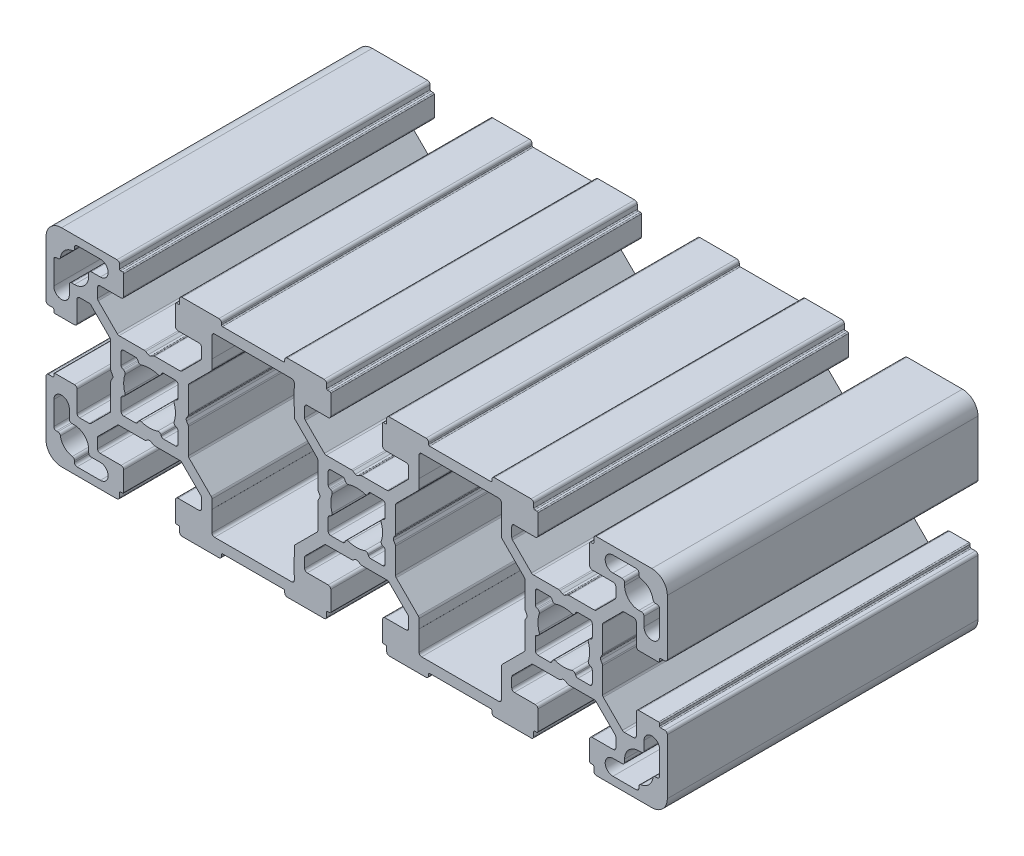
from build123d import *

# Parameters (mm, degrees)
EXTRUDE_1_DEPTH = 60


with BuildPart() as part:
    # Эскиз1 → Бобышка-Вытянуть1 (new body)
    with BuildSketch(Plane.XY):
        with BuildLine():
            Line((-52.669436616, 65.991989417), (-53.169436616, 65.703314282))
            ThreePointArc((-53.169436616, 65.703314282), (-53.419436616, 65.636326984), (-53.669436616, 65.703314282))
            Line((-53.669436616, 65.703314282), (-54.169436616, 65.991989417))
            ThreePointArc((-54.169436616, 65.991989417), (-54.290027094, 66.041939628), (-54.419436616, 66.058976715))
            Line((-54.419436616, 66.058976715), (-59.298116273, 66.058976715))
            ThreePointArc((-59.298116273, 66.058976715), (-59.489457989, 66.097036949), (-59.651669663, 66.205423324))
            Line((-59.651669663, 66.205423324), (-63.322990007, 69.876743668))
            ThreePointArc((-63.322990007, 69.876743668), (-63.431376383, 70.038955342), (-63.469436616, 70.230297059))
            Line((-63.469436616, 70.230297059), (-63.469436616, 72.058976715))
            ThreePointArc((-63.469436616, 72.058976715), (-63.322990007, 72.412530106), (-62.969436616, 72.558976715))
            Line((-62.969436616, 72.558976715), (-58.919436616, 72.558976715))
            ThreePointArc((-58.919436616, 72.558976715), (-58.565883226, 72.705423324), (-58.419436616, 73.058976715))
            Line((-58.419436616, 73.058976715), (-58.419436616, 76.858976715))
            ThreePointArc((-58.419436616, 76.858976715), (-58.47801526, 77.000398071), (-58.619436616, 77.058976715))
            Line((-58.619436616, 77.058976715), (-59.019436616, 77.058976715))
            ThreePointArc((-59.019436616, 77.058976715), (-59.160857973, 77.117555359), (-59.219436616, 77.258976715))
            Line((-59.219436616, 77.258976715), (-59.219436616, 78.058976715))
            ThreePointArc((-59.219436616, 78.058976715), (-59.365883226, 78.412530106), (-59.719436616, 78.558976715))
            Line((-59.719436616, 78.558976715), (-70.419436616, 78.558976715))
            ThreePointArc((-70.419436616, 78.558976715), (-72.54075696, 77.680297059), (-73.419436616, 75.558976715))
            Line((-73.419436616, 75.558976715), (-73.419436616, 64.858976715))
            ThreePointArc((-73.419436616, 64.858976715), (-73.272990007, 64.505423324), (-72.919436616, 64.358976715))
            Line((-72.919436616, 64.358976715), (-72.119436616, 64.358976715))
            ThreePointArc((-72.119436616, 64.358976715), (-71.97801526, 64.300398071), (-71.919436616, 64.158976715))
            Line((-71.919436616, 64.158976715), (-71.919436616, 63.758976715))
            ThreePointArc((-71.919436616, 63.758976715), (-71.860857973, 63.617555359), (-71.719436616, 63.558976715))
            Line((-71.719436616, 63.558976715), (-67.919436616, 63.558976715))
            ThreePointArc((-67.919436616, 63.558976715), (-67.565883226, 63.705423324), (-67.419436616, 64.058976715))
            Line((-67.419436616, 64.058976715), (-67.419436616, 68.108976715))
            ThreePointArc((-67.419436616, 68.108976715), (-67.272990007, 68.462530106), (-66.919436616, 68.608976715))
            Line((-66.919436616, 68.608976715), (-65.09075696, 68.608976715))
            ThreePointArc((-65.09075696, 68.608976715), (-64.899415244, 68.570916481), (-64.737203569, 68.462530106))
            Line((-64.737203569, 68.462530106), (-61.065883226, 64.791209762))
            ThreePointArc((-61.065883226, 64.791209762), (-60.95749685, 64.628998088), (-60.919436616, 64.437656371))
            Line((-60.919436616, 64.437656371), (-60.919436616, 59.558976715))
            ThreePointArc((-60.919436616, 59.558976715), (-60.90239953, 59.429567192), (-60.852449318, 59.308976715))
            Line((-60.852449318, 59.308976715), (-60.563774184, 58.808976715))
            ThreePointArc((-60.563774184, 58.808976715), (-60.496786886, 58.558976715), (-60.563774184, 58.308976715))
            Line((-60.563774184, 58.308976715), (-60.852449318, 57.808976715))
            ThreePointArc((-60.852449318, 57.808976715), (-60.90239953, 57.688386237), (-60.919436616, 57.558976715))
            Line((-60.919436616, 57.558976715), (-60.919436616, 52.680297059))
            ThreePointArc((-60.919436616, 52.680297059), (-60.95749685, 52.488955342), (-61.065883226, 52.326743668))
            Line((-61.065883226, 52.326743668), (-64.737203569, 48.655423324))
            ThreePointArc((-64.737203569, 48.655423324), (-64.899415244, 48.547036949), (-65.09075696, 48.508976715))
            Line((-65.09075696, 48.508976715), (-66.919436616, 48.508976715))
            ThreePointArc((-66.919436616, 48.508976715), (-67.272990007, 48.655423324), (-67.419436616, 49.008976715))
            Line((-67.419436616, 49.008976715), (-67.419436616, 53.058976715))
            ThreePointArc((-67.419436616, 53.058976715), (-67.565883226, 53.412530106), (-67.919436616, 53.558976715))
            Line((-67.919436616, 53.558976715), (-71.719436616, 53.558976715))
            ThreePointArc((-71.719436616, 53.558976715), (-71.860857973, 53.500398071), (-71.919436616, 53.358976715))
            Line((-71.919436616, 53.358976715), (-71.919436616, 52.958976715))
            ThreePointArc((-71.919436616, 52.958976715), (-71.97801526, 52.817555359), (-72.119436616, 52.758976715))
            Line((-72.119436616, 52.758976715), (-72.919436616, 52.758976715))
            ThreePointArc((-72.919436616, 52.758976715), (-73.272990007, 52.612530106), (-73.419436616, 52.258976715))
            Line((-73.419436616, 52.258976715), (-73.419436616, 41.558976715))
            ThreePointArc((-73.419436616, 41.558976715), (-72.54075696, 39.437656371), (-70.419436616, 38.558976715))
            Line((-70.419436616, 38.558976715), (-59.719436616, 38.558976715))
            ThreePointArc((-59.719436616, 38.558976715), (-59.365883226, 38.705423324), (-59.219436616, 39.058976715))
            Line((-59.219436616, 39.058976715), (-59.219436616, 39.858976715))
            ThreePointArc((-59.219436616, 39.858976715), (-59.160857973, 40.000398071), (-59.019436616, 40.058976715))
            Line((-59.019436616, 40.058976715), (-58.619436616, 40.058976715))
            ThreePointArc((-58.619436616, 40.058976715), (-58.47801526, 40.117555359), (-58.419436616, 40.258976715))
            Line((-58.419436616, 40.258976715), (-58.419436616, 44.058976715))
            ThreePointArc((-58.419436616, 44.058976715), (-58.565883226, 44.412530106), (-58.919436616, 44.558976715))
            Line((-58.919436616, 44.558976715), (-62.969436616, 44.558976715))
            ThreePointArc((-62.969436616, 44.558976715), (-63.322990007, 44.705423324), (-63.469436616, 45.058976715))
            Line((-63.469436616, 45.058976715), (-63.469436616, 46.887656371))
            ThreePointArc((-63.469436616, 46.887656371), (-63.431376383, 47.078998088), (-63.322990007, 47.241209762))
            Line((-63.322990007, 47.241209762), (-59.651669663, 50.912530106))
            ThreePointArc((-59.651669663, 50.912530106), (-59.489457989, 51.020916481), (-59.298116273, 51.058976715))
            Line((-59.298116273, 51.058976715), (-54.419436616, 51.058976715))
            ThreePointArc((-54.419436616, 51.058976715), (-54.290027094, 51.076013802), (-54.169436616, 51.125964013))
            Line((-54.169436616, 51.125964013), (-53.669436616, 51.414639148))
            ThreePointArc((-53.669436616, 51.414639148), (-53.419436616, 51.481626446), (-53.169436616, 51.414639148))
            Line((-53.169436616, 51.414639148), (-52.669436616, 51.125964013))
            ThreePointArc((-52.669436616, 51.125964013), (-52.548846139, 51.076013802), (-52.419436616, 51.058976715))
            Line((-52.419436616, 51.058976715), (-47.54075696, 51.058976715))
            ThreePointArc((-47.54075696, 51.058976715), (-47.349415244, 51.020916481), (-47.187203569, 50.912530106))
            Line((-47.187203569, 50.912530106), (-43.515883226, 47.241209762))
            ThreePointArc((-43.515883226, 47.241209762), (-43.40749685, 47.078998088), (-43.369436616, 46.887656371))
            Line((-43.369436616, 46.887656371), (-43.369436616, 45.058976715))
            ThreePointArc((-43.369436616, 45.058976715), (-43.515883226, 44.705423324), (-43.869436616, 44.558976715))
            Line((-43.869436616, 44.558976715), (-47.919436616, 44.558976715))
            ThreePointArc((-47.919436616, 44.558976715), (-48.272990007, 44.412530106), (-48.419436616, 44.058976715))
            Line((-48.419436616, 44.058976715), (-48.419436616, 40.258976715))
            ThreePointArc((-48.419436616, 40.258976715), (-48.360857973, 40.117555359), (-48.219436616, 40.058976715))
            Line((-48.219436616, 40.058976715), (-47.819436616, 40.058976715))
            ThreePointArc((-47.819436616, 40.058976715), (-47.67801526, 40.000398071), (-47.619436616, 39.858976715))
            Line((-47.619436616, 39.858976715), (-47.619436616, 39.058976715))
            ThreePointArc((-47.619436616, 39.058976715), (-47.472990007, 38.705423324), (-47.119436616, 38.558976715))
            Line((-47.119436616, 38.558976715), (-40.029436616, 38.558976715))
            ThreePointArc((-40.029436616, 38.558976715), (-39.675883226, 38.705423324), (-39.529436616, 39.058976715))
            Line((-39.529436616, 39.058976715), (-39.529436616, 39.358976715))
            ThreePointArc((-39.529436616, 39.358976715), (-39.470857973, 39.500398071), (-39.329436616, 39.558976715))
            Line((-39.329436616, 39.558976715), (-27.509436616, 39.558976715))
            ThreePointArc((-27.509436616, 39.558976715), (-27.36801526, 39.500398071), (-27.309436616, 39.358976715))
            Line((-27.309436616, 39.358976715), (-27.309436616, 39.058976715))
            ThreePointArc((-27.309436616, 39.058976715), (-27.162990007, 38.705423324), (-26.809436616, 38.558976715))
            Line((-26.809436616, 38.558976715), (-19.719436616, 38.558976715))
            ThreePointArc((-19.719436616, 38.558976715), (-19.365883226, 38.705423324), (-19.219436616, 39.058976715))
            Line((-19.219436616, 39.058976715), (-19.219436616, 39.858976715))
            ThreePointArc((-19.219436616, 39.858976715), (-19.160857973, 40.000398071), (-19.019436616, 40.058976715))
            Line((-19.019436616, 40.058976715), (-18.619436616, 40.058976715))
            ThreePointArc((-18.619436616, 40.058976715), (-18.47801526, 40.117555359), (-18.419436616, 40.258976715))
            Line((-18.419436616, 40.258976715), (-18.419436616, 44.058976715))
            ThreePointArc((-18.419436616, 44.058976715), (-18.565883226, 44.412530106), (-18.919436616, 44.558976715))
            Line((-18.919436616, 44.558976715), (-22.969436616, 44.558976715))
            ThreePointArc((-22.969436616, 44.558976715), (-23.322990007, 44.705423324), (-23.469436616, 45.058976715))
            Line((-23.469436616, 45.058976715), (-23.469436616, 46.887656371))
            ThreePointArc((-23.469436616, 46.887656371), (-23.431376383, 47.078998088), (-23.322990007, 47.241209762))
            Line((-23.322990007, 47.241209762), (-19.651669663, 50.912530106))
            ThreePointArc((-19.651669663, 50.912530106), (-19.489457989, 51.020916481), (-19.298116273, 51.058976715))
            Line((-19.298116273, 51.058976715), (-14.419436616, 51.058976715))
            ThreePointArc((-14.419436616, 51.058976715), (-14.290027094, 51.076013802), (-14.169436616, 51.125964013))
            Line((-14.169436616, 51.125964013), (-13.669436616, 51.414639148))
            ThreePointArc((-13.669436616, 51.414639148), (-13.419436616, 51.481626446), (-13.169436616, 51.414639148))
            Line((-13.169436616, 51.414639148), (-12.669436616, 51.125964013))
            ThreePointArc((-12.669436616, 51.125964013), (-12.548846139, 51.076013802), (-12.419436616, 51.058976715))
            Line((-12.419436616, 51.058976715), (-7.54075696, 51.058976715))
            ThreePointArc((-7.54075696, 51.058976715), (-7.349415244, 51.020916481), (-7.187203569, 50.912530106))
            Line((-7.187203569, 50.912530106), (-3.515883226, 47.241209762))
            ThreePointArc((-3.515883226, 47.241209762), (-3.40749685, 47.078998088), (-3.369436616, 46.887656371))
            Line((-3.369436616, 46.887656371), (-3.369436616, 45.058976715))
            ThreePointArc((-3.369436616, 45.058976715), (-3.515883226, 44.705423324), (-3.869436616, 44.558976715))
            Line((-3.869436616, 44.558976715), (-7.919436616, 44.558976715))
            ThreePointArc((-7.919436616, 44.558976715), (-8.272990007, 44.412530106), (-8.419436616, 44.058976715))
            Line((-8.419436616, 44.058976715), (-8.419436616, 40.258976715))
            ThreePointArc((-8.419436616, 40.258976715), (-8.360857973, 40.117555359), (-8.219436616, 40.058976715))
            Line((-8.219436616, 40.058976715), (-7.819436616, 40.058976715))
            ThreePointArc((-7.819436616, 40.058976715), (-7.67801526, 40.000398071), (-7.619436616, 39.858976715))
            Line((-7.619436616, 39.858976715), (-7.619436616, 39.058976715))
            ThreePointArc((-7.619436616, 39.058976715), (-7.472990007, 38.705423324), (-7.119436616, 38.558976715))
            Line((-7.119436616, 38.558976715), (-0.029436616, 38.558976715))
            ThreePointArc((-0.029436616, 38.558976715), (0.324116774, 38.705423324), (0.470563384, 39.058976715))
            Line((0.470563384, 39.058976715), (0.470563384, 39.358976715))
            ThreePointArc((0.470563384, 39.358976715), (0.529142027, 39.500398071), (0.670563384, 39.558976715))
            Line((0.670563384, 39.558976715), (12.490563384, 39.558976715))
            ThreePointArc((12.490563384, 39.558976715), (12.63198474, 39.500398071), (12.690563384, 39.358976715))
            Line((12.690563384, 39.358976715), (12.690563384, 39.058976715))
            ThreePointArc((12.690563384, 39.058976715), (12.837009993, 38.705423324), (13.190563384, 38.558976715))
            Line((13.190563384, 38.558976715), (20.280563384, 38.558976715))
            ThreePointArc((20.280563384, 38.558976715), (20.634116774, 38.705423324), (20.780563384, 39.058976715))
            Line((20.780563384, 39.058976715), (20.780563384, 39.858976715))
            ThreePointArc((20.780563384, 39.858976715), (20.839142027, 40.000398071), (20.980563384, 40.058976715))
            Line((20.980563384, 40.058976715), (21.380563384, 40.058976715))
            ThreePointArc((21.380563384, 40.058976715), (21.52198474, 40.117555359), (21.580563384, 40.258976715))
            Line((21.580563384, 40.258976715), (21.580563384, 44.058976715))
            ThreePointArc((21.580563384, 44.058976715), (21.434116774, 44.412530106), (21.080563384, 44.558976715))
            Line((21.080563384, 44.558976715), (17.030563384, 44.558976715))
            ThreePointArc((17.030563384, 44.558976715), (16.677009993, 44.705423324), (16.530563384, 45.058976715))
            Line((16.530563384, 45.058976715), (16.530563384, 46.887656371))
            ThreePointArc((16.530563384, 46.887656371), (16.568623617, 47.078998088), (16.677009993, 47.241209762))
            Line((16.677009993, 47.241209762), (20.348330337, 50.912530106))
            ThreePointArc((20.348330337, 50.912530106), (20.510542011, 51.020916481), (20.701883727, 51.058976715))
            Line((20.701883727, 51.058976715), (25.580563384, 51.058976715))
            ThreePointArc((25.580563384, 51.058976715), (25.709972906, 51.076013802), (25.830563384, 51.125964013))
            Line((25.830563384, 51.125964013), (26.330563384, 51.414639148))
            ThreePointArc((26.330563384, 51.414639148), (26.580563384, 51.481626446), (26.830563384, 51.414639148))
            Line((26.830563384, 51.414639148), (27.330563384, 51.125964013))
            ThreePointArc((27.330563384, 51.125964013), (27.451153861, 51.076013802), (27.580563384, 51.058976715))
            Line((27.580563384, 51.058976715), (32.45924304, 51.058976715))
            ThreePointArc((32.45924304, 51.058976715), (32.650584756, 51.020916481), (32.812796431, 50.912530106))
            Line((32.812796431, 50.912530106), (36.484116774, 47.241209762))
            ThreePointArc((36.484116774, 47.241209762), (36.59250315, 47.078998088), (36.630563384, 46.887656371))
            Line((36.630563384, 46.887656371), (36.630563384, 45.058976715))
            ThreePointArc((36.630563384, 45.058976715), (36.484116774, 44.705423324), (36.130563384, 44.558976715))
            Line((36.130563384, 44.558976715), (32.080563384, 44.558976715))
            ThreePointArc((32.080563384, 44.558976715), (31.727009993, 44.412530106), (31.580563384, 44.058976715))
            Line((31.580563384, 44.058976715), (31.580563384, 40.258976715))
            ThreePointArc((31.580563384, 40.258976715), (31.639142027, 40.117555359), (31.780563384, 40.058976715))
            Line((31.780563384, 40.058976715), (32.180563384, 40.058976715))
            ThreePointArc((32.180563384, 40.058976715), (32.32198474, 40.000398071), (32.380563384, 39.858976715))
            Line((32.380563384, 39.858976715), (32.380563384, 39.058976715))
            ThreePointArc((32.380563384, 39.058976715), (32.527009993, 38.705423324), (32.880563384, 38.558976715))
            Line((32.880563384, 38.558976715), (43.580563384, 38.558976715))
            ThreePointArc((43.580563384, 38.558976715), (45.701883727, 39.437656371), (46.580563384, 41.558976715))
            Line((46.580563384, 41.558976715), (46.580563384, 52.258976715))
            ThreePointArc((46.580563384, 52.258976715), (46.434116774, 52.612530106), (46.080563384, 52.758976715))
            Line((46.080563384, 52.758976715), (45.280563384, 52.758976715))
            ThreePointArc((45.280563384, 52.758976715), (45.139142027, 52.817555359), (45.080563384, 52.958976715))
            Line((45.080563384, 52.958976715), (45.080563384, 53.358976715))
            ThreePointArc((45.080563384, 53.358976715), (45.02198474, 53.500398071), (44.880563384, 53.558976715))
            Line((44.880563384, 53.558976715), (41.080563384, 53.558976715))
            ThreePointArc((41.080563384, 53.558976715), (40.727009993, 53.412530106), (40.580563384, 53.058976715))
            Line((40.580563384, 53.058976715), (40.580563384, 49.008976715))
            ThreePointArc((40.580563384, 49.008976715), (40.434116774, 48.655423324), (40.080563384, 48.508976715))
            Line((40.080563384, 48.508976715), (38.251883727, 48.508976715))
            ThreePointArc((38.251883727, 48.508976715), (38.060542011, 48.547036949), (37.898330337, 48.655423324))
            Line((37.898330337, 48.655423324), (34.227009993, 52.326743668))
            ThreePointArc((34.227009993, 52.326743668), (34.118623617, 52.488955342), (34.080563384, 52.680297059))
            Line((34.080563384, 52.680297059), (34.080563384, 57.558976715))
            ThreePointArc((34.080563384, 57.558976715), (34.063526297, 57.688386237), (34.013576086, 57.808976715))
            Line((34.013576086, 57.808976715), (33.724900951, 58.308976715))
            ThreePointArc((33.724900951, 58.308976715), (33.657913653, 58.558976715), (33.724900951, 58.808976715))
            Line((33.724900951, 58.808976715), (34.013576086, 59.308976715))
            ThreePointArc((34.013576086, 59.308976715), (34.063526297, 59.429567192), (34.080563384, 59.558976715))
            Line((34.080563384, 59.558976715), (34.080563384, 64.437656371))
            ThreePointArc((34.080563384, 64.437656371), (34.118623617, 64.628998088), (34.227009993, 64.791209762))
            Line((34.227009993, 64.791209762), (37.898330337, 68.462530106))
            ThreePointArc((37.898330337, 68.462530106), (38.060542011, 68.570916481), (38.251883727, 68.608976715))
            Line((38.251883727, 68.608976715), (40.080563384, 68.608976715))
            ThreePointArc((40.080563384, 68.608976715), (40.434116774, 68.462530106), (40.580563384, 68.108976715))
            Line((40.580563384, 68.108976715), (40.580563384, 64.058976715))
            ThreePointArc((40.580563384, 64.058976715), (40.727009993, 63.705423324), (41.080563384, 63.558976715))
            Line((41.080563384, 63.558976715), (44.880563384, 63.558976715))
            ThreePointArc((44.880563384, 63.558976715), (45.02198474, 63.617555359), (45.080563384, 63.758976715))
            Line((45.080563384, 63.758976715), (45.080563384, 64.158976715))
            ThreePointArc((45.080563384, 64.158976715), (45.139142027, 64.300398071), (45.280563384, 64.358976715))
            Line((45.280563384, 64.358976715), (46.080563384, 64.358976715))
            ThreePointArc((46.080563384, 64.358976715), (46.434116774, 64.505423324), (46.580563384, 64.858976715))
            Line((46.580563384, 64.858976715), (46.580563384, 75.558976715))
            ThreePointArc((46.580563384, 75.558976715), (45.701883727, 77.680297059), (43.580563384, 78.558976715))
            Line((43.580563384, 78.558976715), (32.880563384, 78.558976715))
            ThreePointArc((32.880563384, 78.558976715), (32.527009993, 78.412530106), (32.380563384, 78.058976715))
            Line((32.380563384, 78.058976715), (32.380563384, 77.258976715))
            ThreePointArc((32.380563384, 77.258976715), (32.32198474, 77.117555359), (32.180563384, 77.058976715))
            Line((32.180563384, 77.058976715), (31.780563384, 77.058976715))
            ThreePointArc((31.780563384, 77.058976715), (31.639142027, 77.000398071), (31.580563384, 76.858976715))
            Line((31.580563384, 76.858976715), (31.580563384, 73.058976715))
            ThreePointArc((31.580563384, 73.058976715), (31.727009993, 72.705423324), (32.080563384, 72.558976715))
            Line((32.080563384, 72.558976715), (36.130563384, 72.558976715))
            ThreePointArc((36.130563384, 72.558976715), (36.484116774, 72.412530106), (36.630563384, 72.058976715))
            Line((36.630563384, 72.058976715), (36.630563384, 70.230297059))
            ThreePointArc((36.630563384, 70.230297059), (36.59250315, 70.038955342), (36.484116774, 69.876743668))
            Line((36.484116774, 69.876743668), (32.812796431, 66.205423324))
            ThreePointArc((32.812796431, 66.205423324), (32.650584756, 66.097036949), (32.45924304, 66.058976715))
            Line((32.45924304, 66.058976715), (27.580563384, 66.058976715))
            ThreePointArc((27.580563384, 66.058976715), (27.451153861, 66.041939628), (27.330563384, 65.991989417))
            Line((27.330563384, 65.991989417), (26.830563384, 65.703314282))
            ThreePointArc((26.830563384, 65.703314282), (26.580563384, 65.636326984), (26.330563384, 65.703314282))
            Line((26.330563384, 65.703314282), (25.830563384, 65.991989417))
            ThreePointArc((25.830563384, 65.991989417), (25.709972906, 66.041939628), (25.580563384, 66.058976715))
            Line((25.580563384, 66.058976715), (20.701883727, 66.058976715))
            ThreePointArc((20.701883727, 66.058976715), (20.510542011, 66.097036949), (20.348330337, 66.205423324))
            Line((20.348330337, 66.205423324), (16.677009993, 69.876743668))
            ThreePointArc((16.677009993, 69.876743668), (16.568623617, 70.038955342), (16.530563384, 70.230297059))
            Line((16.530563384, 70.230297059), (16.530563384, 72.058976715))
            ThreePointArc((16.530563384, 72.058976715), (16.677009993, 72.412530106), (17.030563384, 72.558976715))
            Line((17.030563384, 72.558976715), (21.080563384, 72.558976715))
            ThreePointArc((21.080563384, 72.558976715), (21.434116774, 72.705423324), (21.580563384, 73.058976715))
            Line((21.580563384, 73.058976715), (21.580563384, 76.858976715))
            ThreePointArc((21.580563384, 76.858976715), (21.52198474, 77.000398071), (21.380563384, 77.058976715))
            Line((21.380563384, 77.058976715), (20.980563384, 77.058976715))
            ThreePointArc((20.980563384, 77.058976715), (20.839142027, 77.117555359), (20.780563384, 77.258976715))
            Line((20.780563384, 77.258976715), (20.780563384, 78.058976715))
            ThreePointArc((20.780563384, 78.058976715), (20.634116774, 78.412530106), (20.280563384, 78.558976715))
            Line((20.280563384, 78.558976715), (13.190563384, 78.558976715))
            ThreePointArc((13.190563384, 78.558976715), (12.837009993, 78.412530106), (12.690563384, 78.058976715))
            Line((12.690563384, 78.058976715), (12.690563384, 77.758976715))
            ThreePointArc((12.690563384, 77.758976715), (12.63198474, 77.617555359), (12.490563384, 77.558976715))
            Line((12.490563384, 77.558976715), (0.670563384, 77.558976715))
            ThreePointArc((0.670563384, 77.558976715), (0.529142027, 77.617555359), (0.470563384, 77.758976715))
            Line((0.470563384, 77.758976715), (0.470563384, 78.058976715))
            ThreePointArc((0.470563384, 78.058976715), (0.324116774, 78.412530106), (-0.029436616, 78.558976715))
            Line((-0.029436616, 78.558976715), (-7.119436616, 78.558976715))
            ThreePointArc((-7.119436616, 78.558976715), (-7.472990007, 78.412530106), (-7.619436616, 78.058976715))
            Line((-7.619436616, 78.058976715), (-7.619436616, 77.258976715))
            ThreePointArc((-7.619436616, 77.258976715), (-7.67801526, 77.117555359), (-7.819436616, 77.058976715))
            Line((-7.819436616, 77.058976715), (-8.219436616, 77.058976715))
            ThreePointArc((-8.219436616, 77.058976715), (-8.360857973, 77.000398071), (-8.419436616, 76.858976715))
            Line((-8.419436616, 76.858976715), (-8.419436616, 73.058976715))
            ThreePointArc((-8.419436616, 73.058976715), (-8.272990007, 72.705423324), (-7.919436616, 72.558976715))
            Line((-7.919436616, 72.558976715), (-3.869436616, 72.558976715))
            ThreePointArc((-3.869436616, 72.558976715), (-3.515883226, 72.412530106), (-3.369436616, 72.058976715))
            Line((-3.369436616, 72.058976715), (-3.369436616, 70.230297059))
            ThreePointArc((-3.369436616, 70.230297059), (-3.40749685, 70.038955342), (-3.515883226, 69.876743668))
            Line((-3.515883226, 69.876743668), (-7.187203569, 66.205423324))
            ThreePointArc((-7.187203569, 66.205423324), (-7.349415244, 66.097036949), (-7.54075696, 66.058976715))
            Line((-7.54075696, 66.058976715), (-12.419436616, 66.058976715))
            ThreePointArc((-12.419436616, 66.058976715), (-12.548846139, 66.041939628), (-12.669436616, 65.991989417))
            Line((-12.669436616, 65.991989417), (-13.169436616, 65.703314282))
            ThreePointArc((-13.169436616, 65.703314282), (-13.419436616, 65.636326984), (-13.669436616, 65.703314282))
            Line((-13.669436616, 65.703314282), (-14.169436616, 65.991989417))
            ThreePointArc((-14.169436616, 65.991989417), (-14.290027094, 66.041939628), (-14.419436616, 66.058976715))
            Line((-14.419436616, 66.058976715), (-19.298116273, 66.058976715))
            ThreePointArc((-19.298116273, 66.058976715), (-19.489457989, 66.097036949), (-19.651669663, 66.205423324))
            Line((-19.651669663, 66.205423324), (-23.322990007, 69.876743668))
            ThreePointArc((-23.322990007, 69.876743668), (-23.431376383, 70.038955342), (-23.469436616, 70.230297059))
            Line((-23.469436616, 70.230297059), (-23.469436616, 72.058976715))
            ThreePointArc((-23.469436616, 72.058976715), (-23.322990007, 72.412530106), (-22.969436616, 72.558976715))
            Line((-22.969436616, 72.558976715), (-18.919436616, 72.558976715))
            ThreePointArc((-18.919436616, 72.558976715), (-18.565883226, 72.705423324), (-18.419436616, 73.058976715))
            Line((-18.419436616, 73.058976715), (-18.419436616, 76.858976715))
            ThreePointArc((-18.419436616, 76.858976715), (-18.47801526, 77.000398071), (-18.619436616, 77.058976715))
            Line((-18.619436616, 77.058976715), (-19.019436616, 77.058976715))
            ThreePointArc((-19.019436616, 77.058976715), (-19.160857973, 77.117555359), (-19.219436616, 77.258976715))
            Line((-19.219436616, 77.258976715), (-19.219436616, 78.058976715))
            ThreePointArc((-19.219436616, 78.058976715), (-19.365883226, 78.412530106), (-19.719436616, 78.558976715))
            Line((-19.719436616, 78.558976715), (-26.809436616, 78.558976715))
            ThreePointArc((-26.809436616, 78.558976715), (-27.162990007, 78.412530106), (-27.309436616, 78.058976715))
            Line((-27.309436616, 78.058976715), (-27.309436616, 77.758976715))
            ThreePointArc((-27.309436616, 77.758976715), (-27.36801526, 77.617555359), (-27.509436616, 77.558976715))
            Line((-27.509436616, 77.558976715), (-39.329436616, 77.558976715))
            ThreePointArc((-39.329436616, 77.558976715), (-39.470857973, 77.617555359), (-39.529436616, 77.758976715))
            Line((-39.529436616, 77.758976715), (-39.529436616, 78.058976715))
            ThreePointArc((-39.529436616, 78.058976715), (-39.675883226, 78.412530106), (-40.029436616, 78.558976715))
            Line((-40.029436616, 78.558976715), (-47.119436616, 78.558976715))
            ThreePointArc((-47.119436616, 78.558976715), (-47.472990007, 78.412530106), (-47.619436616, 78.058976715))
            Line((-47.619436616, 78.058976715), (-47.619436616, 77.258976715))
            ThreePointArc((-47.619436616, 77.258976715), (-47.67801526, 77.117555359), (-47.819436616, 77.058976715))
            Line((-47.819436616, 77.058976715), (-48.219436616, 77.058976715))
            ThreePointArc((-48.219436616, 77.058976715), (-48.360857973, 77.000398071), (-48.419436616, 76.858976715))
            Line((-48.419436616, 76.858976715), (-48.419436616, 73.058976715))
            ThreePointArc((-48.419436616, 73.058976715), (-48.272990007, 72.705423324), (-47.919436616, 72.558976715))
            Line((-47.919436616, 72.558976715), (-43.869436616, 72.558976715))
            ThreePointArc((-43.869436616, 72.558976715), (-43.515883226, 72.412530106), (-43.369436616, 72.058976715))
            Line((-43.369436616, 72.058976715), (-43.369436616, 70.230297059))
            ThreePointArc((-43.369436616, 70.230297059), (-43.40749685, 70.038955342), (-43.515883226, 69.876743668))
            Line((-43.515883226, 69.876743668), (-47.187203569, 66.205423324))
            ThreePointArc((-47.187203569, 66.205423324), (-47.349415244, 66.097036949), (-47.54075696, 66.058976715))
            Line((-47.54075696, 66.058976715), (-52.419436616, 66.058976715))
            ThreePointArc((-52.419436616, 66.058976715), (-52.548846139, 66.041939628), (-52.669436616, 65.991989417))
        make_face()
        with BuildLine():
            ThreePointArc((-71.919436616, 49.058976715), (-70.419436616, 50.558976715), (-68.919436616, 49.058976715))
            Line((-68.919436616, 49.058976715), (-68.919436616, 47.308976715))
            ThreePointArc((-68.919436616, 47.308976715), (-68.772990007, 46.955423324), (-68.419436616, 46.808976715))
            Line((-68.419436616, 46.808976715), (-67.919436616, 46.808976715))
            ThreePointArc((-67.919436616, 46.808976715), (-65.974892968, 46.003520363), (-65.169436616, 44.058976715))
            Line((-65.169436616, 44.058976715), (-65.169436616, 43.558976715))
            ThreePointArc((-65.169436616, 43.558976715), (-65.022990007, 43.205423324), (-64.669436616, 43.058976715))
            Line((-64.669436616, 43.058976715), (-62.919436616, 43.058976715))
            ThreePointArc((-62.919436616, 43.058976715), (-61.419436616, 41.558976715), (-62.919436616, 40.058976715))
            Line((-62.919436616, 40.058976715), (-67.419436616, 40.058976715))
            ThreePointArc((-67.419436616, 40.058976715), (-67.772990007, 40.205423324), (-67.919436616, 40.558976715))
            Line((-67.919436616, 40.558976715), (-67.919436616, 40.84766857))
            ThreePointArc((-67.919436616, 40.84766857), (-68.039659354, 41.172890388), (-68.342513539, 41.341715977))
            ThreePointArc((-68.342513539, 41.341715977), (-69.863980265, 42.114433067), (-70.636697354, 43.635899792))
            ThreePointArc((-70.636697354, 43.635899792), (-70.805522943, 43.938753978), (-71.130744761, 44.058976715))
            Line((-71.130744761, 44.058976715), (-71.419436616, 44.058976715))
            ThreePointArc((-71.419436616, 44.058976715), (-71.772990007, 44.205423324), (-71.919436616, 44.558976715))
            Line((-71.919436616, 44.558976715), (-71.919436616, 49.058976715))
        make_face(mode=Mode.SUBTRACT)
        with BuildLine():
            Line((-58.439911428, 60.750473229), (-58.618811151, 60.828261042))
            ThreePointArc((-58.618811151, 60.828261042), (-58.837579694, 61.012644465), (-58.919436616, 61.286791079))
            Line((-58.919436616, 61.286791079), (-58.919436616, 63.558976715))
            ThreePointArc((-58.919436616, 63.558976715), (-58.772990007, 63.912530106), (-58.419436616, 64.058976715))
            Line((-58.419436616, 64.058976715), (-56.147250981, 64.058976715))
            ThreePointArc((-56.147250981, 64.058976715), (-55.873104366, 63.977119793), (-55.688720944, 63.758351249))
            Line((-55.688720944, 63.758351249), (-55.61093313, 63.579451526))
            ThreePointArc((-55.61093313, 63.579451526), (-55.356305675, 63.322291574), (-54.994860686, 63.304294302))
            ThreePointArc((-54.994860686, 63.304294302), (-53.419436616, 63.558976715), (-51.844012547, 63.304294302))
            ThreePointArc((-51.844012547, 63.304294302), (-51.482567558, 63.322291574), (-51.227940103, 63.579451526))
            Line((-51.227940103, 63.579451526), (-51.150152289, 63.758351249))
            ThreePointArc((-51.150152289, 63.758351249), (-50.965768867, 63.977119793), (-50.691622252, 64.058976715))
            Line((-50.691622252, 64.058976715), (-48.419436616, 64.058976715))
            ThreePointArc((-48.419436616, 64.058976715), (-48.065883226, 63.912530106), (-47.919436616, 63.558976715))
            Line((-47.919436616, 63.558976715), (-47.919436616, 61.286791079))
            ThreePointArc((-47.919436616, 61.286791079), (-48.001293538, 61.012644465), (-48.220062082, 60.828261042))
            Line((-48.220062082, 60.828261042), (-48.398961805, 60.750473229))
            ThreePointArc((-48.398961805, 60.750473229), (-48.656121757, 60.495845773), (-48.674119029, 60.134400785))
            ThreePointArc((-48.674119029, 60.134400785), (-48.419436616, 58.558976715), (-48.674119029, 56.983552645))
            ThreePointArc((-48.674119029, 56.983552645), (-48.656121757, 56.622107656), (-48.398961805, 56.367480201))
            Line((-48.398961805, 56.367480201), (-48.220062082, 56.289692388))
            ThreePointArc((-48.220062082, 56.289692388), (-48.001293538, 56.105308965), (-47.919436616, 55.83116235))
            Line((-47.919436616, 55.83116235), (-47.919436616, 53.558976715))
            ThreePointArc((-47.919436616, 53.558976715), (-48.065883226, 53.205423324), (-48.419436616, 53.058976715))
            Line((-48.419436616, 53.058976715), (-50.691622252, 53.058976715))
            ThreePointArc((-50.691622252, 53.058976715), (-50.965768867, 53.140833637), (-51.150152289, 53.35960218))
            Line((-51.150152289, 53.35960218), (-51.227940103, 53.538501904))
            ThreePointArc((-51.227940103, 53.538501904), (-51.482567558, 53.795661856), (-51.844012547, 53.813659128))
            ThreePointArc((-51.844012547, 53.813659128), (-53.419436616, 53.558976715), (-54.994860686, 53.813659128))
            ThreePointArc((-54.994860686, 53.813659128), (-55.356305675, 53.795661856), (-55.61093313, 53.538501904))
            Line((-55.61093313, 53.538501904), (-55.688720944, 53.35960218))
            ThreePointArc((-55.688720944, 53.35960218), (-55.873104366, 53.140833637), (-56.147250981, 53.058976715))
            Line((-56.147250981, 53.058976715), (-58.419436616, 53.058976715))
            ThreePointArc((-58.419436616, 53.058976715), (-58.772990007, 53.205423324), (-58.919436616, 53.558976715))
            Line((-58.919436616, 53.558976715), (-58.919436616, 55.83116235))
            ThreePointArc((-58.919436616, 55.83116235), (-58.837579694, 56.105308965), (-58.618811151, 56.289692388))
            Line((-58.618811151, 56.289692388), (-58.439911428, 56.367480201))
            ThreePointArc((-58.439911428, 56.367480201), (-58.182751476, 56.622107656), (-58.164754203, 56.983552645))
            ThreePointArc((-58.164754203, 56.983552645), (-58.419436616, 58.558976715), (-58.164754203, 60.134400785))
            ThreePointArc((-58.164754203, 60.134400785), (-58.182751476, 60.495845773), (-58.439911428, 60.750473229))
        make_face(mode=Mode.SUBTRACT)
        with BuildLine():
            Line((-8.398961805, 56.367480201), (-8.220062082, 56.289692388))
            ThreePointArc((-8.220062082, 56.289692388), (-8.001293538, 56.105308965), (-7.919436616, 55.83116235))
            Line((-7.919436616, 55.83116235), (-7.919436616, 53.558976715))
            ThreePointArc((-7.919436616, 53.558976715), (-8.065883226, 53.205423324), (-8.419436616, 53.058976715))
            Line((-8.419436616, 53.058976715), (-10.691622252, 53.058976715))
            ThreePointArc((-10.691622252, 53.058976715), (-10.965768867, 53.140833637), (-11.150152289, 53.35960218))
            Line((-11.150152289, 53.35960218), (-11.227940103, 53.538501904))
            ThreePointArc((-11.227940103, 53.538501904), (-11.482567558, 53.795661856), (-11.844012547, 53.813659128))
            ThreePointArc((-11.844012547, 53.813659128), (-13.419436616, 53.558976715), (-14.994860686, 53.813659128))
            ThreePointArc((-14.994860686, 53.813659128), (-15.356305675, 53.795661856), (-15.61093313, 53.538501904))
            Line((-15.61093313, 53.538501904), (-15.688720944, 53.35960218))
            ThreePointArc((-15.688720944, 53.35960218), (-15.873104366, 53.140833637), (-16.147250981, 53.058976715))
            Line((-16.147250981, 53.058976715), (-18.419436616, 53.058976715))
            ThreePointArc((-18.419436616, 53.058976715), (-18.772990007, 53.205423324), (-18.919436616, 53.558976715))
            Line((-18.919436616, 53.558976715), (-18.919436616, 55.83116235))
            ThreePointArc((-18.919436616, 55.83116235), (-18.837579694, 56.105308965), (-18.618811151, 56.289692388))
            Line((-18.618811151, 56.289692388), (-18.439911428, 56.367480201))
            ThreePointArc((-18.439911428, 56.367480201), (-18.182751476, 56.622107656), (-18.164754203, 56.983552645))
            ThreePointArc((-18.164754203, 56.983552645), (-18.419436616, 58.558976715), (-18.164754203, 60.134400785))
            ThreePointArc((-18.164754203, 60.134400785), (-18.182751476, 60.495845773), (-18.439911428, 60.750473229))
            Line((-18.439911428, 60.750473229), (-18.618811151, 60.828261042))
            ThreePointArc((-18.618811151, 60.828261042), (-18.837579694, 61.012644465), (-18.919436616, 61.286791079))
            Line((-18.919436616, 61.286791079), (-18.919436616, 63.558976715))
            ThreePointArc((-18.919436616, 63.558976715), (-18.772990007, 63.912530106), (-18.419436616, 64.058976715))
            Line((-18.419436616, 64.058976715), (-16.147250981, 64.058976715))
            ThreePointArc((-16.147250981, 64.058976715), (-15.873104366, 63.977119793), (-15.688720944, 63.758351249))
            Line((-15.688720944, 63.758351249), (-15.61093313, 63.579451526))
            ThreePointArc((-15.61093313, 63.579451526), (-15.356305675, 63.322291574), (-14.994860686, 63.304294302))
            ThreePointArc((-14.994860686, 63.304294302), (-13.419436616, 63.558976715), (-11.844012547, 63.304294302))
            ThreePointArc((-11.844012547, 63.304294302), (-11.482567558, 63.322291574), (-11.227940103, 63.579451526))
            Line((-11.227940103, 63.579451526), (-11.150152289, 63.758351249))
            ThreePointArc((-11.150152289, 63.758351249), (-10.965768867, 63.977119793), (-10.691622252, 64.058976715))
            Line((-10.691622252, 64.058976715), (-8.419436616, 64.058976715))
            ThreePointArc((-8.419436616, 64.058976715), (-8.065883226, 63.912530106), (-7.919436616, 63.558976715))
            Line((-7.919436616, 63.558976715), (-7.919436616, 61.286791079))
            ThreePointArc((-7.919436616, 61.286791079), (-8.001293538, 61.012644465), (-8.220062082, 60.828261042))
            Line((-8.220062082, 60.828261042), (-8.398961805, 60.750473229))
            ThreePointArc((-8.398961805, 60.750473229), (-8.656121757, 60.495845773), (-8.674119029, 60.134400785))
            ThreePointArc((-8.674119029, 60.134400785), (-8.419436616, 58.558976715), (-8.674119029, 56.983552645))
            ThreePointArc((-8.674119029, 56.983552645), (-8.656121757, 56.622107656), (-8.398961805, 56.367480201))
        make_face(mode=Mode.SUBTRACT)
        with BuildLine():
            Line((41.080563384, 40.84766857), (41.080563384, 40.558976715))
            ThreePointArc((41.080563384, 40.558976715), (40.934116774, 40.205423324), (40.580563384, 40.058976715))
            Line((40.580563384, 40.058976715), (36.080563384, 40.058976715))
            ThreePointArc((36.080563384, 40.058976715), (34.580563384, 41.558976715), (36.080563384, 43.058976715))
            Line((36.080563384, 43.058976715), (37.830563384, 43.058976715))
            ThreePointArc((37.830563384, 43.058976715), (38.184116774, 43.205423324), (38.330563384, 43.558976715))
            Line((38.330563384, 43.558976715), (38.330563384, 44.058976715))
            ThreePointArc((38.330563384, 44.058976715), (39.136019735, 46.003520363), (41.080563384, 46.808976715))
            Line((41.080563384, 46.808976715), (41.580563384, 46.808976715))
            ThreePointArc((41.580563384, 46.808976715), (41.934116774, 46.955423324), (42.080563384, 47.308976715))
            Line((42.080563384, 47.308976715), (42.080563384, 49.058976715))
            ThreePointArc((42.080563384, 49.058976715), (43.580563384, 50.558976715), (45.080563384, 49.058976715))
            Line((45.080563384, 49.058976715), (45.080563384, 44.558976715))
            ThreePointArc((45.080563384, 44.558976715), (44.934116774, 44.205423324), (44.580563384, 44.058976715))
            Line((44.580563384, 44.058976715), (44.291871528, 44.058976715))
            ThreePointArc((44.291871528, 44.058976715), (43.96664971, 43.938753978), (43.797824121, 43.635899792))
            ThreePointArc((43.797824121, 43.635899792), (43.025107032, 42.114433067), (41.503640307, 41.341715977))
            ThreePointArc((41.503640307, 41.341715977), (41.200786121, 41.172890388), (41.080563384, 40.84766857))
        make_face(mode=Mode.SUBTRACT)
        with BuildLine():
            Line((31.601038195, 56.367480201), (31.779937918, 56.289692388))
            ThreePointArc((31.779937918, 56.289692388), (31.998706462, 56.105308965), (32.080563384, 55.83116235))
            Line((32.080563384, 55.83116235), (32.080563384, 53.558976715))
            ThreePointArc((32.080563384, 53.558976715), (31.934116774, 53.205423324), (31.580563384, 53.058976715))
            Line((31.580563384, 53.058976715), (29.308377748, 53.058976715))
            ThreePointArc((29.308377748, 53.058976715), (29.034231133, 53.140833637), (28.849847711, 53.35960218))
            Line((28.849847711, 53.35960218), (28.772059897, 53.538501904))
            ThreePointArc((28.772059897, 53.538501904), (28.517432442, 53.795661856), (28.155987453, 53.813659128))
            ThreePointArc((28.155987453, 53.813659128), (26.580563384, 53.558976715), (25.005139314, 53.813659128))
            ThreePointArc((25.005139314, 53.813659128), (24.643694325, 53.795661856), (24.38906687, 53.538501904))
            Line((24.38906687, 53.538501904), (24.311279056, 53.35960218))
            ThreePointArc((24.311279056, 53.35960218), (24.126895634, 53.140833637), (23.852749019, 53.058976715))
            Line((23.852749019, 53.058976715), (21.580563384, 53.058976715))
            ThreePointArc((21.580563384, 53.058976715), (21.227009993, 53.205423324), (21.080563384, 53.558976715))
            Line((21.080563384, 53.558976715), (21.080563384, 55.83116235))
            ThreePointArc((21.080563384, 55.83116235), (21.162420306, 56.105308965), (21.381188849, 56.289692388))
            Line((21.381188849, 56.289692388), (21.560088572, 56.367480201))
            ThreePointArc((21.560088572, 56.367480201), (21.817248524, 56.622107656), (21.835245797, 56.983552645))
            ThreePointArc((21.835245797, 56.983552645), (21.580563384, 58.558976715), (21.835245797, 60.134400785))
            ThreePointArc((21.835245797, 60.134400785), (21.817248524, 60.495845773), (21.560088572, 60.750473229))
            Line((21.560088572, 60.750473229), (21.381188849, 60.828261042))
            ThreePointArc((21.381188849, 60.828261042), (21.162420306, 61.012644465), (21.080563384, 61.286791079))
            Line((21.080563384, 61.286791079), (21.080563384, 63.558976715))
            ThreePointArc((21.080563384, 63.558976715), (21.227009993, 63.912530106), (21.580563384, 64.058976715))
            Line((21.580563384, 64.058976715), (23.852749019, 64.058976715))
            ThreePointArc((23.852749019, 64.058976715), (24.126895634, 63.977119793), (24.311279056, 63.758351249))
            Line((24.311279056, 63.758351249), (24.38906687, 63.579451526))
            ThreePointArc((24.38906687, 63.579451526), (24.643694325, 63.322291574), (25.005139314, 63.304294302))
            ThreePointArc((25.005139314, 63.304294302), (26.580563384, 63.558976715), (28.155987453, 63.304294302))
            ThreePointArc((28.155987453, 63.304294302), (28.517432442, 63.322291574), (28.772059897, 63.579451526))
            Line((28.772059897, 63.579451526), (28.849847711, 63.758351249))
            ThreePointArc((28.849847711, 63.758351249), (29.034231133, 63.977119793), (29.308377748, 64.058976715))
            Line((29.308377748, 64.058976715), (31.580563384, 64.058976715))
            ThreePointArc((31.580563384, 64.058976715), (31.934116774, 63.912530106), (32.080563384, 63.558976715))
            Line((32.080563384, 63.558976715), (32.080563384, 61.286791079))
            ThreePointArc((32.080563384, 61.286791079), (31.998706462, 61.012644465), (31.779937918, 60.828261042))
            Line((31.779937918, 60.828261042), (31.601038195, 60.750473229))
            ThreePointArc((31.601038195, 60.750473229), (31.343878243, 60.495845773), (31.325880971, 60.134400785))
            ThreePointArc((31.325880971, 60.134400785), (31.580563384, 58.558976715), (31.325880971, 56.983552645))
            ThreePointArc((31.325880971, 56.983552645), (31.343878243, 56.622107656), (31.601038195, 56.367480201))
        make_face(mode=Mode.SUBTRACT)
        with BuildLine():
            Line((-42.101669663, 48.655423324), (-45.772990007, 52.326743668))
            ThreePointArc((-45.772990007, 52.326743668), (-45.881376383, 52.488955342), (-45.919436616, 52.680297059))
            Line((-45.919436616, 52.680297059), (-45.919436616, 57.558976715))
            ThreePointArc((-45.919436616, 57.558976715), (-45.936473703, 57.688386237), (-45.986423914, 57.808976715))
            Line((-45.986423914, 57.808976715), (-46.275099049, 58.308976715))
            ThreePointArc((-46.275099049, 58.308976715), (-46.342086347, 58.558976715), (-46.275099049, 58.808976715))
            Line((-46.275099049, 58.808976715), (-45.986423914, 59.308976715))
            ThreePointArc((-45.986423914, 59.308976715), (-45.936473703, 59.429567192), (-45.919436616, 59.558976715))
            Line((-45.919436616, 59.558976715), (-45.919436616, 64.437656371))
            ThreePointArc((-45.919436616, 64.437656371), (-45.881376383, 64.628998088), (-45.772990007, 64.791209762))
            Line((-45.772990007, 64.791209762), (-42.101669663, 68.462530106))
            Line((-42.101669663, 68.462530106), (-41.515883226, 69.048316543))
            ThreePointArc((-41.515883226, 69.048316543), (-41.40749685, 69.210528218), (-41.369436616, 69.401869934))
            Line((-41.369436616, 69.401869934), (-41.369436616, 71.144636887))
            Line((-41.369436616, 71.144636887), (-41.354446236, 71.139106279))
            Line((-41.354446236, 71.139106279), (-41.367735071, 75.057280931))
            ThreePointArc((-41.367735071, 75.057280931), (-41.22189038, 75.411930046), (-40.867737947, 75.558976715))
            Line((-40.867737947, 75.558976715), (-25.971135286, 75.558976715))
            ThreePointArc((-25.971135286, 75.558976715), (-25.616982853, 75.411930046), (-25.471138162, 75.057280931))
            Line((-25.471138162, 75.057280931), (-25.484426997, 71.139106279))
            Line((-25.484426997, 71.139106279), (-25.469436616, 71.144636887))
            Line((-25.469436616, 71.144636887), (-25.469436616, 69.401869934))
            ThreePointArc((-25.469436616, 69.401869934), (-25.431376383, 69.210528218), (-25.322990007, 69.048316543))
            Line((-25.322990007, 69.048316543), (-24.737203569, 68.462530106))
            Line((-24.737203569, 68.462530106), (-21.065883226, 64.791209762))
            ThreePointArc((-21.065883226, 64.791209762), (-20.95749685, 64.628998088), (-20.919436616, 64.437656371))
            Line((-20.919436616, 64.437656371), (-20.919436616, 59.558976715))
            ThreePointArc((-20.919436616, 59.558976715), (-20.90239953, 59.429567192), (-20.852449318, 59.308976715))
            Line((-20.852449318, 59.308976715), (-20.563774184, 58.808976715))
            ThreePointArc((-20.563774184, 58.808976715), (-20.496786886, 58.558976715), (-20.563774184, 58.308976715))
            Line((-20.563774184, 58.308976715), (-20.852449318, 57.808976715))
            ThreePointArc((-20.852449318, 57.808976715), (-20.90239953, 57.688386237), (-20.919436616, 57.558976715))
            Line((-20.919436616, 57.558976715), (-20.919436616, 52.680297059))
            ThreePointArc((-20.919436616, 52.680297059), (-20.95749685, 52.488955342), (-21.065883226, 52.326743668))
            Line((-21.065883226, 52.326743668), (-24.737203569, 48.655423324))
            Line((-24.737203569, 48.655423324), (-25.322990007, 48.069636887))
            ThreePointArc((-25.322990007, 48.069636887), (-25.431376383, 47.907425212), (-25.469436616, 47.716083496))
            Line((-25.469436616, 47.716083496), (-25.469436616, 45.973316543))
            Line((-25.469436616, 45.973316543), (-25.484426997, 45.978847151))
            Line((-25.484426997, 45.978847151), (-25.471138162, 42.060672499))
            ThreePointArc((-25.471138162, 42.060672499), (-25.616982853, 41.706023384), (-25.971135286, 41.558976715))
            Line((-25.971135286, 41.558976715), (-40.867737947, 41.558976715))
            ThreePointArc((-40.867737947, 41.558976715), (-41.22189038, 41.706023384), (-41.367735071, 42.060672499))
            Line((-41.367735071, 42.060672499), (-41.354446236, 45.978847151))
            Line((-41.354446236, 45.978847151), (-41.369436616, 45.973316543))
            Line((-41.369436616, 45.973316543), (-41.369436616, 47.716083496))
            ThreePointArc((-41.369436616, 47.716083496), (-41.40749685, 47.907425212), (-41.515883226, 48.069636887))
            Line((-41.515883226, 48.069636887), (-42.101669663, 48.655423324))
        make_face(mode=Mode.SUBTRACT)
        with BuildLine():
            Line((-67.919436616, 76.27028486), (-67.919436616, 76.558976715))
            ThreePointArc((-67.919436616, 76.558976715), (-67.772990007, 76.912530106), (-67.419436616, 77.058976715))
            Line((-67.419436616, 77.058976715), (-62.919436616, 77.058976715))
            ThreePointArc((-62.919436616, 77.058976715), (-61.419436616, 75.558976715), (-62.919436616, 74.058976715))
            Line((-62.919436616, 74.058976715), (-64.669436616, 74.058976715))
            ThreePointArc((-64.669436616, 74.058976715), (-65.022990007, 73.912530106), (-65.169436616, 73.558976715))
            Line((-65.169436616, 73.558976715), (-65.169436616, 73.058976715))
            ThreePointArc((-65.169436616, 73.058976715), (-65.974892968, 71.114433067), (-67.919436616, 70.308976715))
            Line((-67.919436616, 70.308976715), (-68.419436616, 70.308976715))
            ThreePointArc((-68.419436616, 70.308976715), (-68.772990007, 70.162530106), (-68.919436616, 69.808976715))
            Line((-68.919436616, 69.808976715), (-68.919436616, 68.058976715))
            ThreePointArc((-68.919436616, 68.058976715), (-70.419436616, 66.558976715), (-71.919436616, 68.058976715))
            Line((-71.919436616, 68.058976715), (-71.919436616, 72.558976715))
            ThreePointArc((-71.919436616, 72.558976715), (-71.772990007, 72.912530106), (-71.419436616, 73.058976715))
            Line((-71.419436616, 73.058976715), (-71.130744761, 73.058976715))
            ThreePointArc((-71.130744761, 73.058976715), (-70.805522943, 73.179199452), (-70.636697354, 73.482053638))
            ThreePointArc((-70.636697354, 73.482053638), (-69.863980265, 75.003520363), (-68.342513539, 75.776237453))
            ThreePointArc((-68.342513539, 75.776237453), (-68.039659354, 75.945063042), (-67.919436616, 76.27028486))
        make_face(mode=Mode.SUBTRACT)
        with BuildLine():
            Line((-2.101669663, 48.655423324), (-5.772990007, 52.326743668))
            ThreePointArc((-5.772990007, 52.326743668), (-5.881376383, 52.488955342), (-5.919436616, 52.680297059))
            Line((-5.919436616, 52.680297059), (-5.919436616, 57.558976715))
            ThreePointArc((-5.919436616, 57.558976715), (-5.936473703, 57.688386237), (-5.986423914, 57.808976715))
            Line((-5.986423914, 57.808976715), (-6.275099049, 58.308976715))
            ThreePointArc((-6.275099049, 58.308976715), (-6.342086347, 58.558976715), (-6.275099049, 58.808976715))
            Line((-6.275099049, 58.808976715), (-5.986423914, 59.308976715))
            ThreePointArc((-5.986423914, 59.308976715), (-5.936473703, 59.429567192), (-5.919436616, 59.558976715))
            Line((-5.919436616, 59.558976715), (-5.919436616, 64.437656371))
            ThreePointArc((-5.919436616, 64.437656371), (-5.881376383, 64.628998088), (-5.772990007, 64.791209762))
            Line((-5.772990007, 64.791209762), (-2.101669663, 68.462530106))
            Line((-2.101669663, 68.462530106), (-1.515883226, 69.048316543))
            ThreePointArc((-1.515883226, 69.048316543), (-1.40749685, 69.210528218), (-1.369436616, 69.401869934))
            Line((-1.369436616, 69.401869934), (-1.369436616, 71.144636887))
            Line((-1.369436616, 71.144636887), (-1.354446236, 71.139106279))
            Line((-1.354446236, 71.139106279), (-1.367735071, 75.057280931))
            ThreePointArc((-1.367735071, 75.057280931), (-1.22189038, 75.411930046), (-0.867737947, 75.558976715))
            Line((-0.867737947, 75.558976715), (14.028864714, 75.558976715))
            ThreePointArc((14.028864714, 75.558976715), (14.383017147, 75.411930046), (14.528861838, 75.057280931))
            Line((14.528861838, 75.057280931), (14.515573003, 71.139106279))
            Line((14.515573003, 71.139106279), (14.530563384, 71.144636887))
            Line((14.530563384, 71.144636887), (14.530563384, 69.401869934))
            ThreePointArc((14.530563384, 69.401869934), (14.568623617, 69.210528218), (14.677009993, 69.048316543))
            Line((14.677009993, 69.048316543), (15.262796431, 68.462530106))
            Line((15.262796431, 68.462530106), (18.934116774, 64.791209762))
            ThreePointArc((18.934116774, 64.791209762), (19.04250315, 64.628998088), (19.080563384, 64.437656371))
            Line((19.080563384, 64.437656371), (19.080563384, 59.558976715))
            ThreePointArc((19.080563384, 59.558976715), (19.09760047, 59.429567192), (19.147550682, 59.308976715))
            Line((19.147550682, 59.308976715), (19.436225816, 58.808976715))
            ThreePointArc((19.436225816, 58.808976715), (19.503213114, 58.558976715), (19.436225816, 58.308976715))
            Line((19.436225816, 58.308976715), (19.147550682, 57.808976715))
            ThreePointArc((19.147550682, 57.808976715), (19.09760047, 57.688386237), (19.080563384, 57.558976715))
            Line((19.080563384, 57.558976715), (19.080563384, 52.680297059))
            ThreePointArc((19.080563384, 52.680297059), (19.04250315, 52.488955342), (18.934116774, 52.326743668))
            Line((18.934116774, 52.326743668), (15.262796431, 48.655423324))
            Line((15.262796431, 48.655423324), (14.677009993, 48.069636887))
            ThreePointArc((14.677009993, 48.069636887), (14.568623617, 47.907425212), (14.530563384, 47.716083496))
            Line((14.530563384, 47.716083496), (14.530563384, 45.973316543))
            Line((14.530563384, 45.973316543), (14.515573003, 45.978847151))
            Line((14.515573003, 45.978847151), (14.528861838, 42.060672499))
            ThreePointArc((14.528861838, 42.060672499), (14.383017147, 41.706023384), (14.028864714, 41.558976715))
            Line((14.028864714, 41.558976715), (-0.867737947, 41.558976715))
            ThreePointArc((-0.867737947, 41.558976715), (-1.22189038, 41.706023384), (-1.367735071, 42.060672499))
            Line((-1.367735071, 42.060672499), (-1.354446236, 45.978847151))
            Line((-1.354446236, 45.978847151), (-1.369436616, 45.973316543))
            Line((-1.369436616, 45.973316543), (-1.369436616, 47.716083496))
            ThreePointArc((-1.369436616, 47.716083496), (-1.40749685, 47.907425212), (-1.515883226, 48.069636887))
            Line((-1.515883226, 48.069636887), (-2.101669663, 48.655423324))
        make_face(mode=Mode.SUBTRACT)
        with BuildLine():
            ThreePointArc((45.080563384, 68.058976715), (43.580563384, 66.558976715), (42.080563384, 68.058976715))
            Line((42.080563384, 68.058976715), (42.080563384, 69.808976715))
            ThreePointArc((42.080563384, 69.808976715), (41.934116774, 70.162530106), (41.580563384, 70.308976715))
            Line((41.580563384, 70.308976715), (41.080563384, 70.308976715))
            ThreePointArc((41.080563384, 70.308976715), (39.136019735, 71.114433067), (38.330563384, 73.058976715))
            Line((38.330563384, 73.058976715), (38.330563384, 73.558976715))
            ThreePointArc((38.330563384, 73.558976715), (38.184116774, 73.912530106), (37.830563384, 74.058976715))
            Line((37.830563384, 74.058976715), (36.080563384, 74.058976715))
            ThreePointArc((36.080563384, 74.058976715), (34.580563384, 75.558976715), (36.080563384, 77.058976715))
            Line((36.080563384, 77.058976715), (40.580563384, 77.058976715))
            ThreePointArc((40.580563384, 77.058976715), (40.934116774, 76.912530106), (41.080563384, 76.558976715))
            Line((41.080563384, 76.558976715), (41.080563384, 76.27028486))
            ThreePointArc((41.080563384, 76.27028486), (41.200786121, 75.945063042), (41.503640307, 75.776237453))
            ThreePointArc((41.503640307, 75.776237453), (43.025107032, 75.003520363), (43.797824121, 73.482053638))
            ThreePointArc((43.797824121, 73.482053638), (43.96664971, 73.179199452), (44.291871528, 73.058976715))
            Line((44.291871528, 73.058976715), (44.580563384, 73.058976715))
            ThreePointArc((44.580563384, 73.058976715), (44.934116774, 72.912530106), (45.080563384, 72.558976715))
            Line((45.080563384, 72.558976715), (45.080563384, 68.058976715))
        make_face(mode=Mode.SUBTRACT)
    extrude(amount=EXTRUDE_1_DEPTH)


solid = part.part
